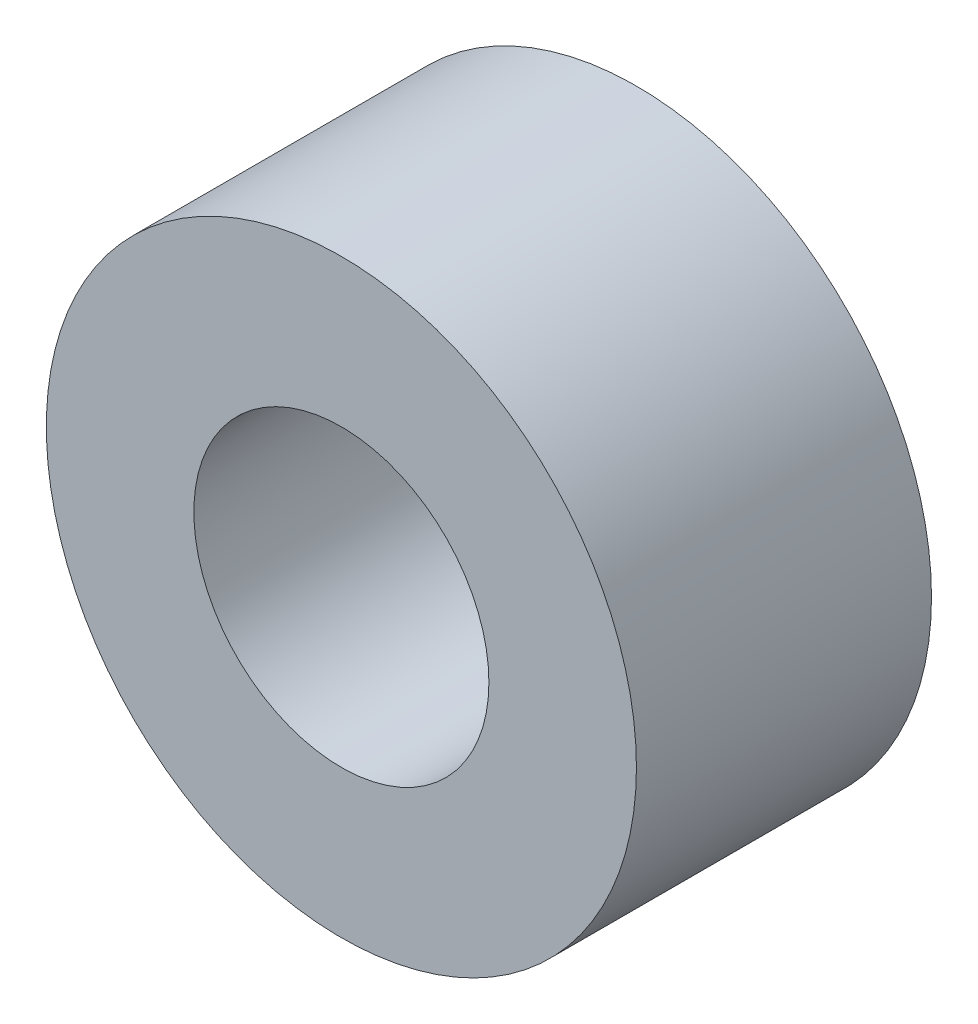
from build123d import *

# Parameters (mm, degrees)
SKETCH1_R           = 12.7
BOSS_EXTRUDE1_DEPTH = 12.7
SKETCH2_R           = 6.35
CUT_EXTRUDE1_DEPTH  = 12.7


with BuildPart() as part:
    # Sketch1 → Boss-Extrude1 (new body)
    with BuildSketch(Plane.XY):
        Circle(SKETCH1_R)
    extrude(amount=BOSS_EXTRUDE1_DEPTH)

    # Sketch2 → Cut-Extrude1 (cut)
    with BuildSketch(Plane.XY.offset(12.7)):
        Circle(SKETCH2_R)
    extrude(amount=-CUT_EXTRUDE1_DEPTH, mode=Mode.SUBTRACT)


solid = part.part
